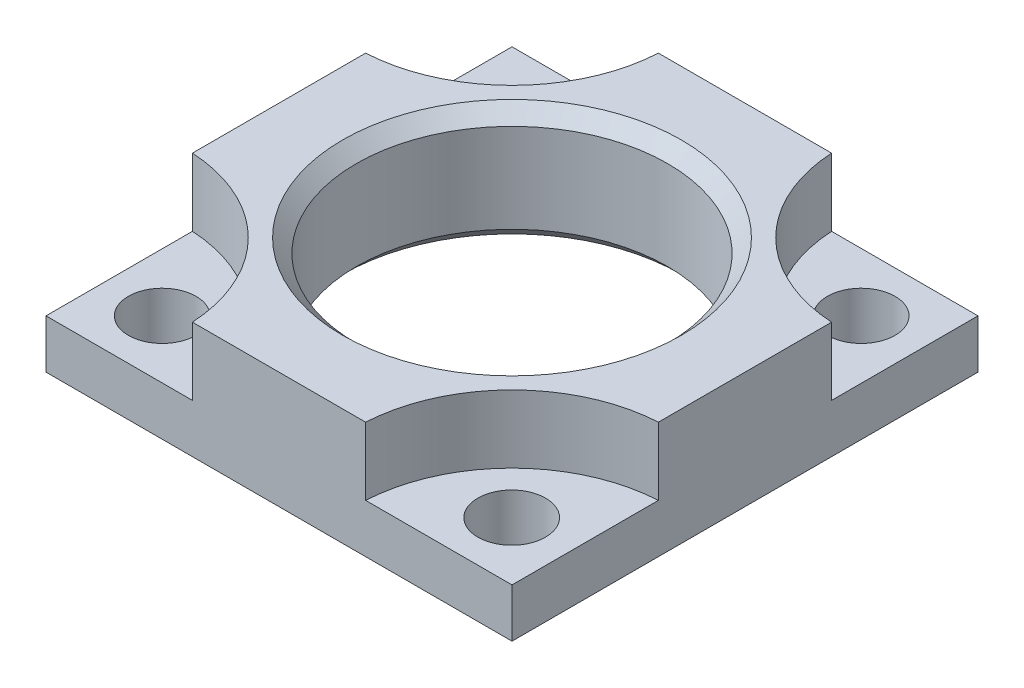
from build123d import *

# Parameters (mm, degrees)
SKETCH1_W          = 38.1
SKETCH1_H          = 38.1
SKETCH1_R          = 12.7254
EXTRUDE1_DEPTH     = 9.525
CUT_EXTRUDE1_DEPTH = 5.5372
HOLE1_D            = 5.5372
HOLE1_DEPTH        = 3.9878


with BuildPart() as part:
    # Sketch1 → Extrude1 (new body)
    with BuildSketch(Plane(origin=(0, 0, 0), x_dir=(1, 0, 0), z_dir=(0, 1, 0))):
        Rectangle(SKETCH1_W, SKETCH1_H)
        with Locations(Location((0, 0, 0), (0, 0, 270))):  # turned: the seam where the file's is
            Circle(SKETCH1_R, mode=Mode.SUBTRACT)
    extrude(amount=EXTRUDE1_DEPTH)

    # Sketch2 → Cut-Extrude1 (cut)
    with BuildSketch(Plane(origin=(0, 9.525, 0), x_dir=(1, 0, 0), z_dir=(0, 1, 0))):
        with BuildLine():
            Line((7.081129237, -19.05), (19.05, -19.05))
            Line((19.05, -19.05), (19.05, -7.081129237))
            ThreePointArc((19.05, -7.081129237), (10.780943879, -10.780943879), (7.081129237, -19.05))
        make_face()
        with BuildLine():
            Line((19.05, 19.05), (19.05, 7.081129237))
            ThreePointArc((19.05, 7.081129237), (10.780943879, 10.780943879), (7.081129237, 19.05))
            Line((7.081129237, 19.05), (19.05, 19.05))
        make_face()
        with BuildLine():
            Line((-7.081129237, 19.05), (-19.05, 19.05))
            Line((-19.05, 19.05), (-19.05, 7.081129237))
            ThreePointArc((-19.05, 7.081129237), (-10.780943879, 10.780943879), (-7.081129237, 19.05))
        make_face()
        with BuildLine():
            Line((-19.05, -19.05), (-19.05, -7.081129237))
            ThreePointArc((-19.05, -7.081129237), (-10.780943879, -10.780943879), (-7.081129237, -19.05))
            Line((-7.081129237, -19.05), (-19.05, -19.05))
        make_face()
    extrude(amount=-CUT_EXTRUDE1_DEPTH, mode=Mode.SUBTRACT)

    # Hole1
    with Locations(Plane(origin=(0, 3.9878, 0), x_dir=(-1, 0, 0), z_dir=(0, 1, 0))):
        with Locations((14.3002, 14.3002), (14.3002, -14.2748), (-14.2748, 14.3002), (-14.2748, -14.2748)):
            Hole(HOLE1_D / 2, depth=HOLE1_DEPTH)

    # Sketch5 → Cut-Revolve1 (revolve, cut)
    with BuildSketch(Plane(origin=(0, 0, 0), x_dir=(0, 0, -1), z_dir=(1, 0, 0)), mode=Mode.PRIVATE) as cut_revolve1_sk:
        Polygon((-13.843, 9.525), (-12.7254, 9.525), (-12.7254, 8.4074), align=None)
        Polygon((-12.7254, 1.1176), (-13.843, 0), (-12.7254, 0), align=None)
    revolve(cut_revolve1_sk.sketch.rotate(Axis((0, 0, 0), (0, 1, 0)), 180), axis=Axis((0, 0, 0), (0, 1, 0)), mode=Mode.SUBTRACT)  # turned: the seam where the file's is


solid = part.part
